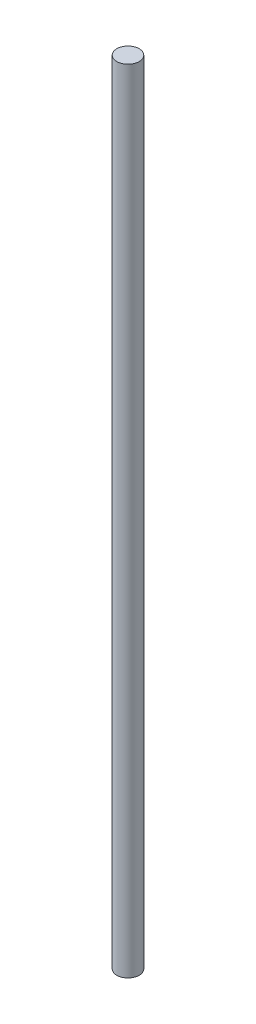
from build123d import *

# Parameters (mm, degrees)
SKETCH1_R           = 6.35
BOSS_EXTRUDE1_DEPTH = 450


with BuildPart() as part:
    # Sketch1 → Boss-Extrude1 (new body)
    with BuildSketch(Plane(origin=(0, 0, 0), x_dir=(1, 0, 0), z_dir=(0, 1, 0))):
        Circle(SKETCH1_R)
    extrude(amount=BOSS_EXTRUDE1_DEPTH)


solid = part.part
